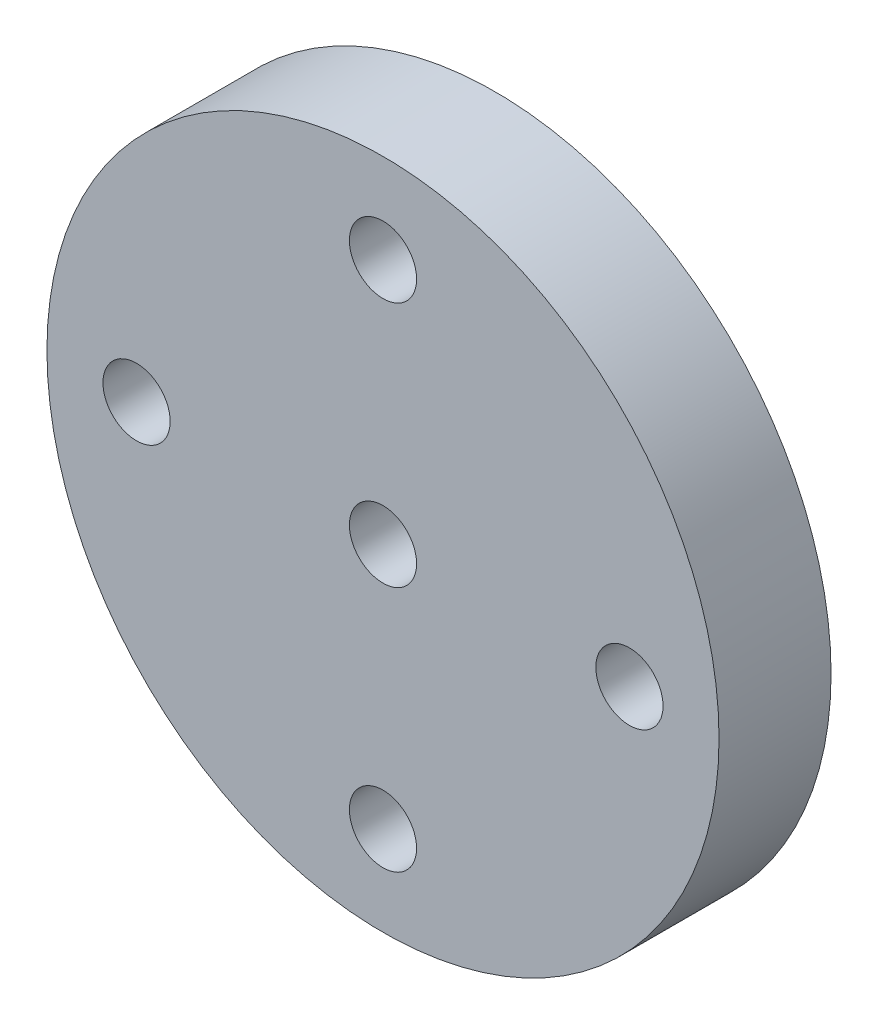
from build123d import *

# Parameters (mm, degrees)
SKETCH_2_R      = 15
SKETCH_2_R_2    = 1.5
EXTRUDE_1_DEPTH = 5


with BuildPart() as part:
    # 草图2 → 凸台-拉伸1 (new body)
    with BuildSketch(Plane.XY):
        with Locations((2507.640054531, 4716.002927903)):
            Circle(SKETCH_2_R)
        with Locations((2507.640054531, 4716.002927903)):
            Circle(SKETCH_2_R_2, mode=Mode.SUBTRACT)
        with Locations((2507.640054531, 4705.002927903)):
            Circle(SKETCH_2_R_2, mode=Mode.SUBTRACT)
        with Locations((2507.640054531, 4727.002927903)):
            Circle(SKETCH_2_R_2, mode=Mode.SUBTRACT)
        with Locations((2496.640054531, 4716.002927903)):
            Circle(SKETCH_2_R_2, mode=Mode.SUBTRACT)
        with Locations((2518.640054531, 4716.002927903)):
            Circle(SKETCH_2_R_2, mode=Mode.SUBTRACT)
    extrude(amount=EXTRUDE_1_DEPTH)


solid = part.part
